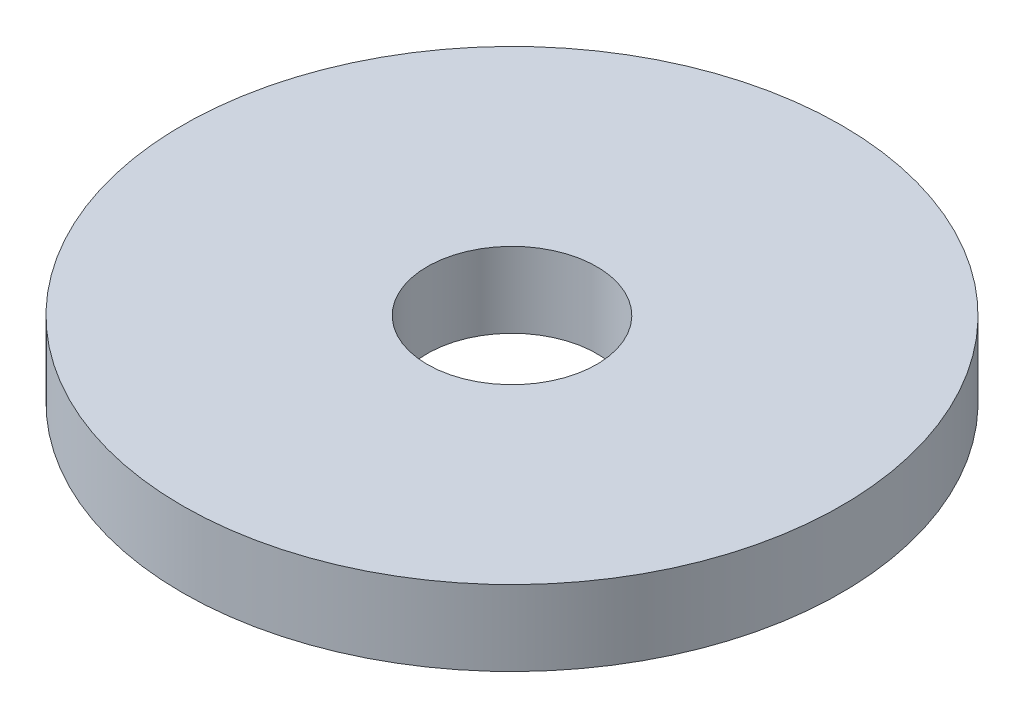
from build123d import *

# Parameters (mm, degrees)
SKETCH1_R      = 3.5
SKETCH1_R_2    = 0.9
EXTRUDE1_DEPTH = 0.8


with BuildPart() as part:
    # Sketch1 → Extrude1 (new body)
    with BuildSketch(Plane(origin=(0, 0, 0), x_dir=(1, 0, 0), z_dir=(0, 1, 0))):
        with Locations(Location((0, 0, 0), (0, 0, 270))):  # turned: the seam where the file's is
            Circle(SKETCH1_R)
        with Locations(Location((0, 0, 0), (0, 0, 270))):  # turned: the seam where the file's is
            Circle(SKETCH1_R_2, mode=Mode.SUBTRACT)
    extrude(amount=EXTRUDE1_DEPTH)


solid = part.part
